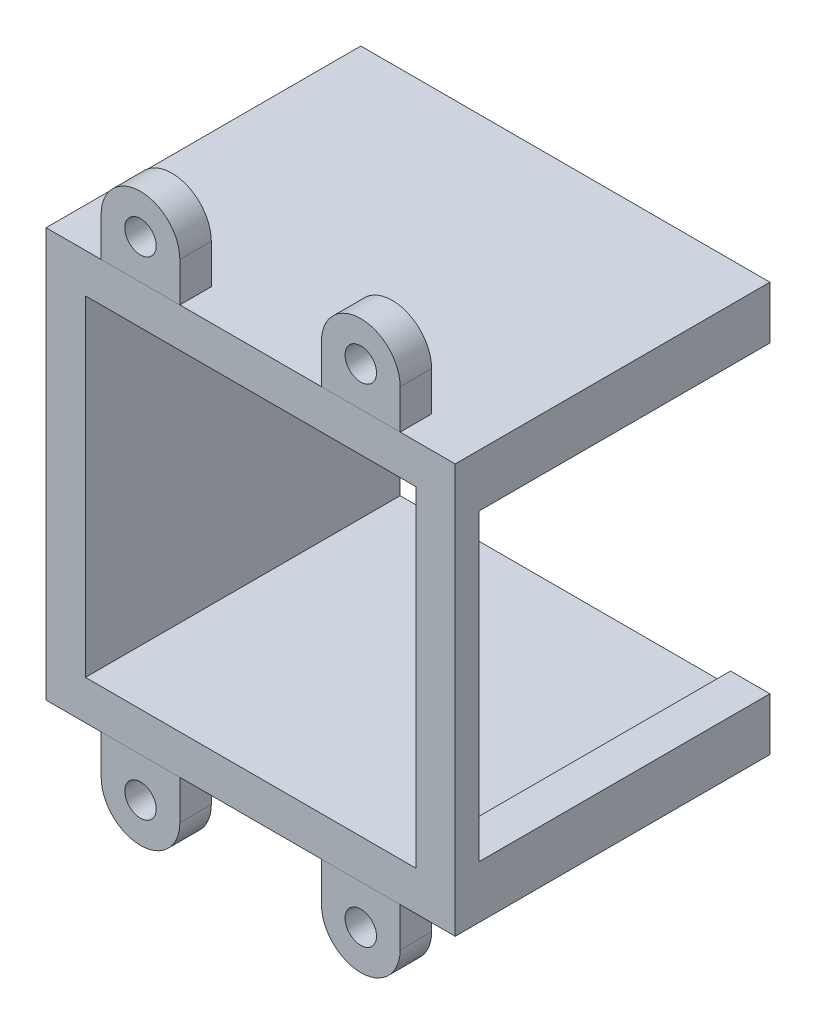
from build123d import *

# Parameters (mm, degrees)
SKETCH_2_W          = 52
SKETCH_2_H          = 52
EXTRUDE_1_DEPTH     = 40
SKETCH_1_W          = 42
SKETCH_1_H          = 42
CUT_EXTRUDE_1_DEPTH = 40
CUT_EXTRUDE_2_REACH = 54
SKETCH_4_W          = 37
SKETCH_4_H          = 38.6
SKETCH_5_R          = 2
EXTRUDE_2_DEPTH     = 4
EXTRUDE_2_2_DEPTH   = 4
EXTRUDE_2_3_DEPTH   = 4
EXTRUDE_2_4_DEPTH   = 4


with BuildPart() as part:
    # 草圖2 → 填料-伸長1 (new body)
    with BuildSketch(Plane.XY):
        Rectangle(SKETCH_2_W, SKETCH_2_H)
    extrude(amount=EXTRUDE_1_DEPTH)

    # 草圖1 → 除料-伸長1 (cut)
    with BuildSketch(Plane.XY):
        Rectangle(SKETCH_1_W, SKETCH_1_H)
    extrude(amount=CUT_EXTRUDE_1_DEPTH, mode=Mode.SUBTRACT)

    # 草圖4 → 除料-伸長2 (cut, up to next)
    with BuildSketch(Plane(origin=(26, 0, 0), x_dir=(0, 0, -1), z_dir=(1, 0, 0)), mode=Mode.PRIVATE) as cut_extrude_2_sk1:
        with Locations((-18.5, 0)):
            Rectangle(SKETCH_4_W, SKETCH_4_H)
    cut_extrude_2_tool1 = extrude(cut_extrude_2_sk1.sketch, amount=-CUT_EXTRUDE_2_REACH, mode=Mode.PRIVATE) & part.part
    add(cut_extrude_2_tool1.solids().sort_by_distance((26, 0, 18.5))[0], mode=Mode.SUBTRACT)


with BuildPart() as body_2:
    # 草圖5 → 填料-伸長2 (new body)
    with BuildSketch(Plane.XY.offset(40)):
        with BuildLine():
            Line((-19, 26), (-19, 31))
            ThreePointArc((-19, 31), (-14, 36), (-9, 31))
            Line((-9, 31), (-9, 26))
            Line((-9, 26), (-19, 26))
        make_face()
        with Locations((-14, 31)):
            Circle(SKETCH_5_R, mode=Mode.SUBTRACT)
    extrude(amount=-EXTRUDE_2_DEPTH)


with BuildPart() as body_3:
    # 草圖5 → Extrude 2 2 (new body)
    with BuildSketch(Plane.XY.offset(40)):
        with BuildLine():
            Line((19, 31), (19, 26))
            Line((19, 26), (9, 26))
            Line((9, 26), (9, 31))
            ThreePointArc((9, 31), (14, 36), (19, 31))
        make_face()
        with Locations((14, 31)):
            Circle(SKETCH_5_R, mode=Mode.SUBTRACT)
    extrude(amount=-EXTRUDE_2_2_DEPTH)


with BuildPart() as body_4:
    # 草圖5 → Extrude 2 3 (new body)
    with BuildSketch(Plane.XY.offset(40)):
        with BuildLine():
            Line((9, -26), (9, -31))
            ThreePointArc((9, -31), (14, -36), (19, -31))
            Line((19, -31), (19, -26))
            Line((19, -26), (9, -26))
        make_face()
        with Locations((14, -31)):
            Circle(SKETCH_5_R, mode=Mode.SUBTRACT)
    extrude(amount=-EXTRUDE_2_3_DEPTH)


with BuildPart() as body_5:
    # 草圖5 → Extrude 2 4 (new body)
    with BuildSketch(Plane.XY.offset(40)):
        with BuildLine():
            Line((-9, -26), (-19, -26))
            Line((-19, -26), (-19, -31))
            ThreePointArc((-19, -31), (-14, -36), (-9, -31))
            Line((-9, -31), (-9, -26))
        make_face()
        with Locations((-14, -31)):
            Circle(SKETCH_5_R, mode=Mode.SUBTRACT)
    extrude(amount=-EXTRUDE_2_4_DEPTH)


solid = Compound([part.part, body_2.part, body_3.part, body_4.part, body_5.part])
